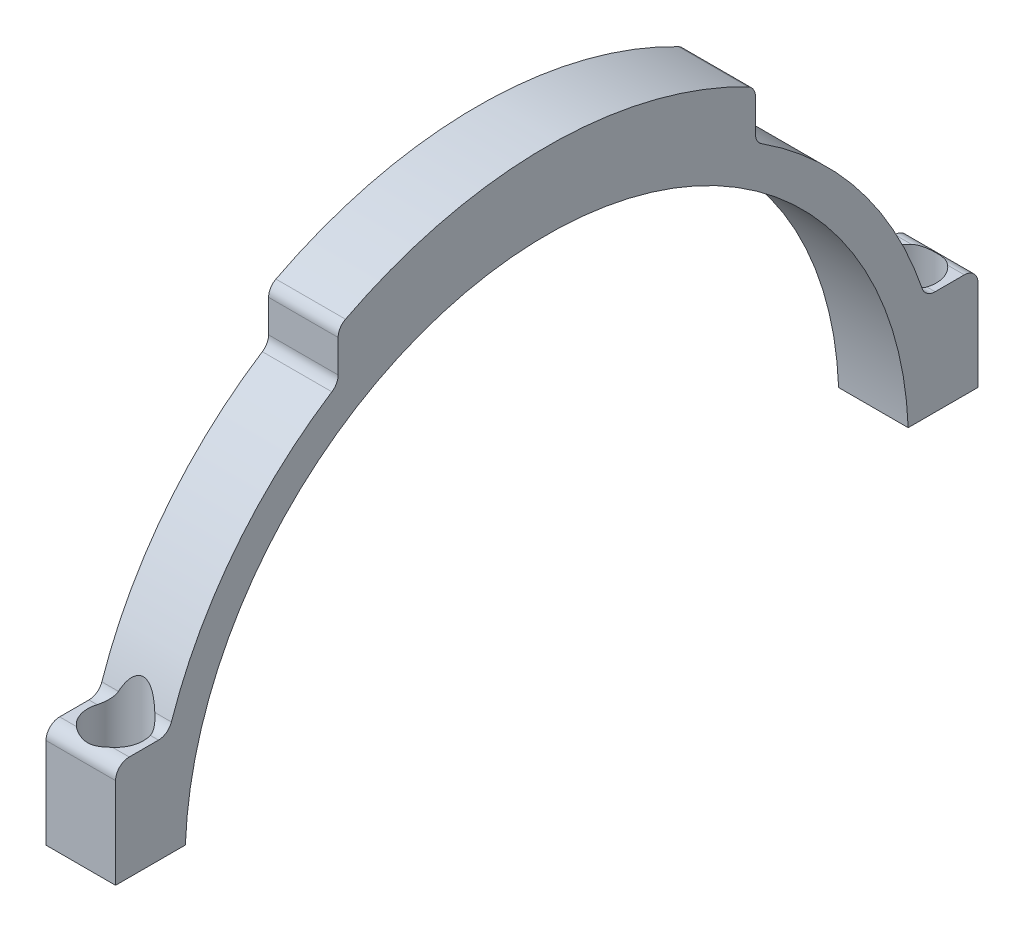
from build123d import *

# Parameters (mm, degrees)
BOSS_EXTRUDE1_DEPTH                        = 10
CBORE_FOR_M4_CHEESE_HEAD_SCREW1_AT_2_COUNT = 2
CBORE_FOR_M4_CHEESE_HEAD_SCREW1_AT_2_PITCH = 114
SKETCH6_R                                  = 4
CUT_EXTRUDE1_DEPTH                         = 8


with BuildPart() as part:
    # Sketch1 → Boss-Extrude1 (new body)
    with BuildSketch(Plane(origin=(0, 0, 0), x_dir=(0, 0, -1), z_dir=(1, 0, 0))):
        with BuildLine():
            Line((30, 49.547642934), (30, 54.216993929))
            ThreePointArc((30, 54.216993929), (29.713903717, 55.237294084), (28.93903477, 55.960095305))
            ThreePointArc((28.93903477, 55.960095305), (0, 63), (-28.93903477, 55.960095305))
            ThreePointArc((-28.93903477, 55.960095305), (-29.713903717, 55.237294084), (-30, 54.216993929))
            Line((-30, 54.216993929), (-30, 49.547642934))
            ThreePointArc((-30, 49.547642934), (-30.239236403, 48.608646152), (-30.898614566, 47.898597244))
            ThreePointArc((-30.898614566, 47.898597244), (-44.936698638, 35.066980416), (-53.971882891, 18.331280838))
            ThreePointArc((-53.971882891, 18.331280838), (-54.687108259, 17.367169566), (-55.830018745, 17))
            Line((-55.830018745, 17), (-60.037612586, 17))
            ThreePointArc((-60.037612586, 17), (-61.425230034, 16.425230034), (-62, 15.037612586))
            Line((-62, 15.037612586), (-62, 2))
            Line((-62, 2), (-51.961524227, 2))
            ThreePointArc((-51.961524227, 2), (0, 52), (51.961524227, 2))
            Line((51.961524227, 2), (62, 2))
            Line((62, 2), (62, 15.037612586))
            ThreePointArc((62, 15.037612586), (61.425230034, 16.425230034), (60.037612586, 17))
            Line((60.037612586, 17), (55.830018745, 17))
            ThreePointArc((55.830018745, 17), (54.687108259, 17.367169566), (53.971882891, 18.331280838))
            ThreePointArc((53.971882891, 18.331280838), (44.936698638, 35.066980416), (30.898614566, 47.898597244))
            ThreePointArc((30.898614566, 47.898597244), (30.239236403, 48.608646152), (30, 49.547642934))
        make_face()
    extrude(amount=BOSS_EXTRUDE1_DEPTH)

    # Sketch4 → CBORE for M4 Cheese Head Screw1 (revolve, cut)
    with BuildSketch(Plane(origin=(5, 17, -57), x_dir=(0, 0, 1), z_dir=(1, 0, 0))):
        Polygon((0, 0), (0, 21.291850331), (2.15, 20), (2.15, 6.6), (4, 6.6), (4, 0), align=None)
    cbore_for_m4_cheese_head_screw1 = revolve(axis=Axis((5, 23.35, -57), (0, -1, 0)), mode=Mode.SUBTRACT)

    # CBORE for M4 Cheese Head Screw1 at 2: CBORE for M4 Cheese Head Screw1 ×2
    with Locations(*[(0, 0, i * CBORE_FOR_M4_CHEESE_HEAD_SCREW1_AT_2_PITCH) for i in range(1, CBORE_FOR_M4_CHEESE_HEAD_SCREW1_AT_2_COUNT)]):
        add(cbore_for_m4_cheese_head_screw1, mode=Mode.SUBTRACT)

    # Sketch6 → Cut-Extrude1 (cut)
    with BuildSketch(Plane(origin=(0, 17, 0), x_dir=(1, 0, 0), z_dir=(0, 1, 0))):
        with Locations((5, 57)):
            Circle(SKETCH6_R)
        with Locations((5, -57)):
            Circle(SKETCH6_R)
    extrude(amount=CUT_EXTRUDE1_DEPTH, mode=Mode.SUBTRACT)


solid = part.part
